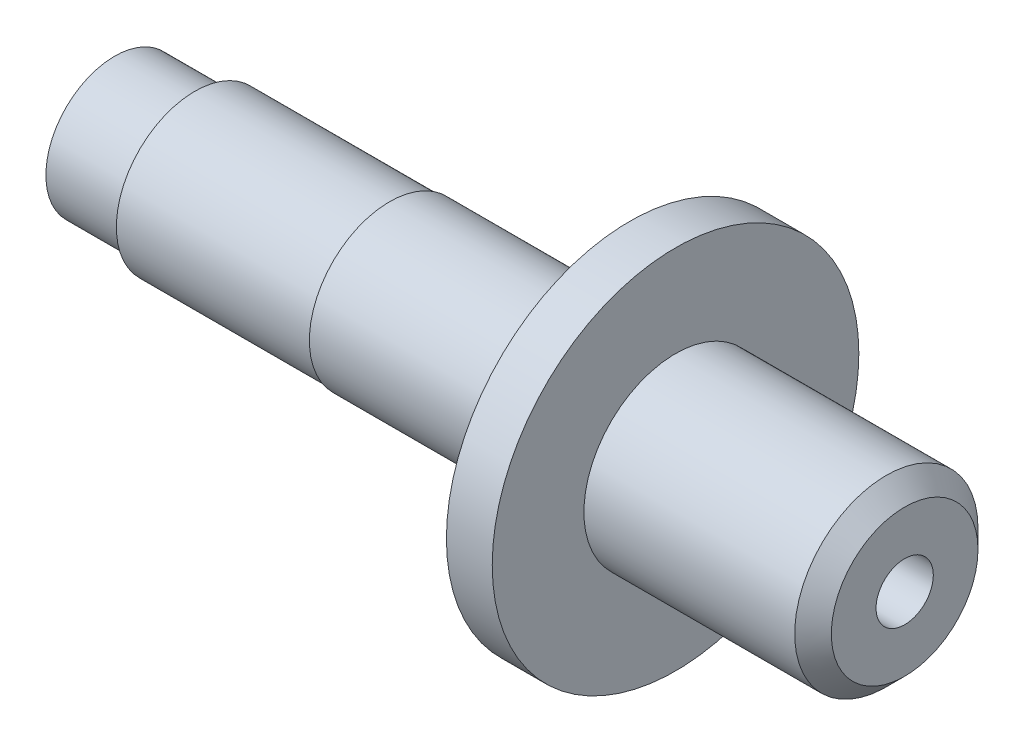
from build123d import *

# Parameters (mm, degrees)
SKETCH5_R          = 3.96875
CUT_EXTRUDE1_DEPTH = 28.575
SKETCH6_R          = 3.96875
CUT_EXTRUDE2_DEPTH = 33.782
CHAMFER1_SIZE      = 2.54


with BuildPart() as part:
    # Sketch4 → Revolve2 (revolve)
    with BuildSketch(Plane.XY):
        with BuildLine():
            Line((0, 0), (0, 9.525))
            Line((0, 9.525), (11.1125, 9.525))
            Line((11.1125, 9.525), (11.1125, 10.8712))
            Line((11.1125, 10.8712), (38.1, 10.8712))
            Line((38.1, 10.8712), (38.1, 11.1125))
            Line((38.1, 11.1125), (65.024, 11.1125))
            Line((65.024, 11.1125), (65.024, 12.7))
            Line((65.024, 12.7), (66.294, 12.7))
            ThreePointArc((66.294, 12.7), (69.886102448, 14.187897552), (71.374, 17.78))
            Line((71.374, 17.78), (71.374, 25.4))
            Line((71.374, 25.4), (77.724, 25.4))
            Line((77.724, 25.4), (77.724, 12.7))
            Line((77.724, 12.7), (109.474, 12.7))
            Line((109.474, 12.7), (109.474, 0))
            Line((109.474, 0), (0, 0))
        make_face()
    revolve(axis=Axis((109.474, 0, 0), (-1, 0, 0)))

    # Sketch5 → Cut-Extrude1 (cut)
    with BuildSketch(Plane.ZY):
        Circle(SKETCH5_R)
    extrude(amount=-CUT_EXTRUDE1_DEPTH, mode=Mode.SUBTRACT)

    # Sketch6 → Cut-Extrude2 (cut)
    with BuildSketch(Plane(origin=(109.474, 0, 0), x_dir=(0, 0, -1), z_dir=(1, 0, 0))):
        Circle(SKETCH6_R)
    extrude(amount=-CUT_EXTRUDE2_DEPTH, mode=Mode.SUBTRACT)

    # Chamfer1
    chamfer1_edges = [part.edges().sort_by_distance(p)[0] for p in [
        (109.474, -12.7, 0),
    ]]
    chamfer(chamfer1_edges, length=CHAMFER1_SIZE)


solid = part.part
